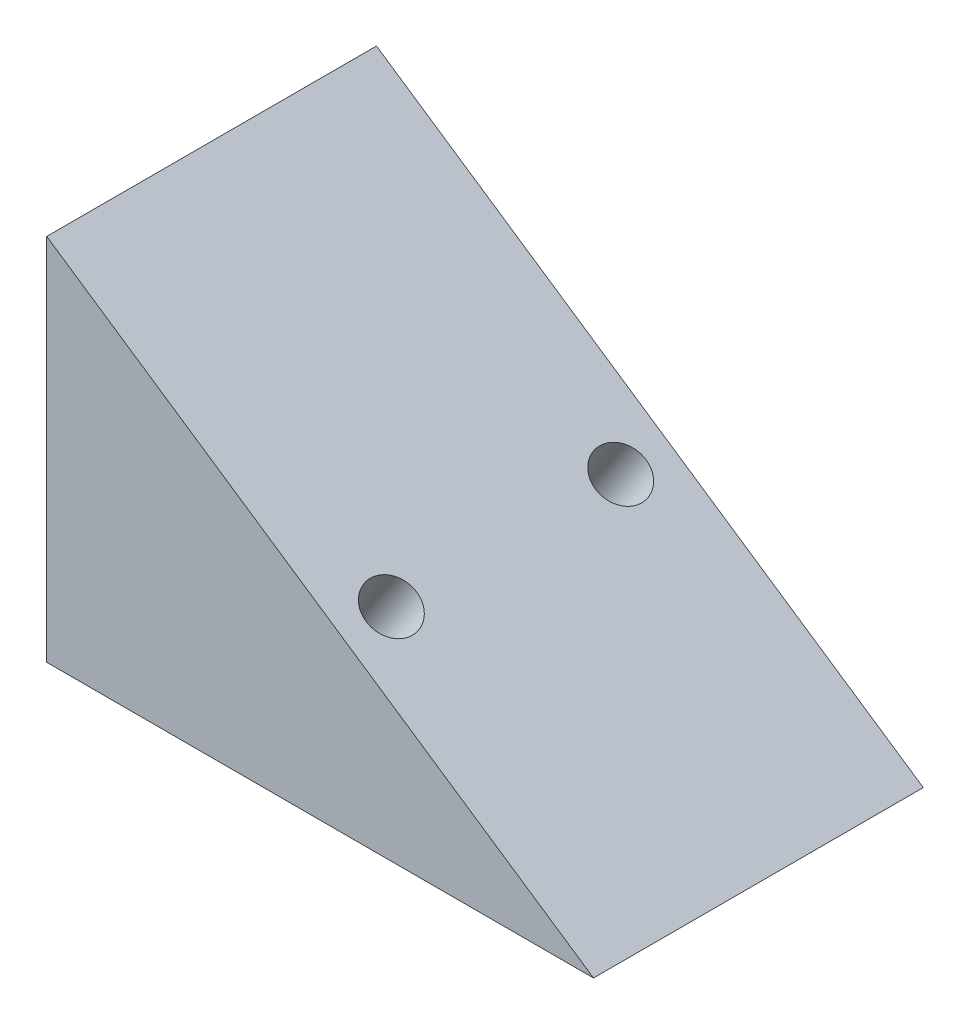
from build123d import *

# Parameters (mm, degrees)
BOSS_EXTRU_1_DEPTH      = 130
ESQUISSE3_R             = 10
ENL_V_MAT_EXTRU_1_DEPTH = 40
CONG_1_R                = 2
CONG_2_R                = 2


with BuildPart() as part:
    # Esquisse2 → Boss.-Extru.1 (new body)
    with BuildSketch(Plane.XY):
        Polygon((0, 0), (-215.549768864, 0), (-215.549768864, 145.390154902), align=None)
    extrude(amount=BOSS_EXTRU_1_DEPTH)

    # Esquisse3 → Enlèv. mat.-Extru.1 (cut)
    with BuildSketch(Plane(origin=(0, 0, 0), x_dir=(0.829037573, -0.559192903, 0), z_dir=(0.559192903, 0.829037573, 0))):
        with Locations((-120, -19.80283687)):
            Circle(ESQUISSE3_R)
        with Locations((-120, -110.19716313)):
            Circle(ESQUISSE3_R)
    extrude(amount=-ENL_V_MAT_EXTRU_1_DEPTH, mode=Mode.SUBTRACT)

    # Congé1
    cong_1_edges = [part.edges().sort_by_distance(p)[0] for p in [
        (-130.142600571, 39.533574549, 19.80283687),
    ]]
    fillet(cong_1_edges, radius=CONG_1_R)

    # Congé2
    cong_2_edges = [part.edges().sort_by_distance(p)[0] for p in [
        (-130.142600571, 39.533574549, 110.19716313),
    ]]
    fillet(cong_2_edges, radius=CONG_2_R)


solid = part.part
